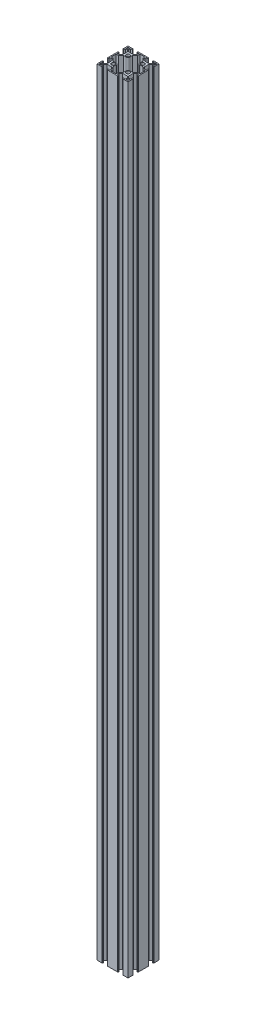
from build123d import *

# Parameters (mm, degrees)
SKETCH1_W                = 60
SKETCH1_H                = 60
BOSS_EXTRUDE1_DEPTH      = 1500
CUT_EXTRUDE1_DEPTH       = 1501.599880048
CIRPATTERN1_COUNT        = 4
CIRPATTERN1_COPY_1_DEPTH = 1501.599880048
CIRPATTERN1_COPY_2_DEPTH = 1501.599880048
CIRPATTERN1_COPY_3_DEPTH = 1501.599880048
SKETCH4_R                = 3.4
CUT_EXTRUDE2_DEPTH       = 1501.599880048
FILLET1_R                = 0.2
FILLET2_R                = 0.2
FILLET3_R                = 0.2
FILLET4_R                = 0.2


with BuildPart() as part:
    # Sketch1 → Boss-Extrude1 (new body)
    with BuildSketch(Plane(origin=(0, 0, 0), x_dir=(1, 0, 0), z_dir=(0, 1, 0))):
        Rectangle(SKETCH1_W, SKETCH1_H)
        Polygon((-23.05, -28), (-6.95, -28), (-6.95, -24.4), (-10.615, -20.8), (-19.385, -20.8), (-23.05, -24.4), align=None, mode=Mode.SUBTRACT)
        Polygon((10.615, -20.8), (19.385, -20.8), (23.05, -24.4), (23.05, -28), (6.95, -28), (6.95, -24.4), align=None, mode=Mode.SUBTRACT)
        Polygon((19.385, 20.8), (23.05, 24.4), (23.05, 28), (6.95, 28), (6.95, 24.4), (10.615, 20.8), align=None, mode=Mode.SUBTRACT)
        Polygon((-23.05, 24.4), (-23.05, 28), (-6.95, 28), (-6.95, 24.4), (-10.615, 20.8), (-19.385, 20.8), align=None, mode=Mode.SUBTRACT)
        Polygon((-20.8, 19.385), (-24.4, 23.05), (-28, 23.05), (-28, 6.95), (-24.4, 6.95), (-20.8, 10.615), align=None, mode=Mode.SUBTRACT)
        Polygon((-24.4, -23.05), (-28, -23.05), (-28, -6.95), (-24.4, -6.95), (-20.8, -10.615), (-20.8, -19.385), align=None, mode=Mode.SUBTRACT)
        Polygon((20.8, -19.385), (24.4, -23.05), (28, -23.05), (28, -6.95), (24.4, -6.95), (20.8, -10.615), align=None, mode=Mode.SUBTRACT)
        Polygon((24.4, 23.05), (28, 23.05), (28, 6.95), (24.4, 6.95), (20.8, 10.615), (20.8, 19.385), align=None, mode=Mode.SUBTRACT)
    extrude(amount=BOSS_EXTRUDE1_DEPTH)

    # Sketch2 → Cut-Extrude1 (cut, through all)
    with BuildSketch(Plane(origin=(0, 1500, 0), x_dir=(1, 0, 0), z_dir=(0, 1, 0))):
        Polygon((-19.1, -28), (-19.1, -29), (-20.1, -29), (-20.1, -30), (-9.9, -30), (-9.9, -29), (-10.9, -29), (-10.9, -28), align=None)
    cut_extrude1 = extrude(amount=-CUT_EXTRUDE1_DEPTH, mode=Mode.SUBTRACT)

    # Mirror1: Cut-Extrude1 across plane
    add(cut_extrude1.mirror(Plane(origin=(0, 0, 0), x_dir=(0, 0, 1), z_dir=(1, 0, 0))), mode=Mode.SUBTRACT)

    # CirPattern1: Cut-Extrude1 ×4 about axis
    cirpattern1_axis = Axis((0, 1050, 0), (0, -1, 0))
    for i in range(1, CIRPATTERN1_COUNT):
        add(cut_extrude1.rotate(cirpattern1_axis, i * 360 / CIRPATTERN1_COUNT), mode=Mode.SUBTRACT)

    # CirPattern1 copy 1 sketch → CirPattern1 copy 1 (cut, through all)
    with BuildSketch(Plane(origin=(0, 1500, 0), x_dir=(0, 0, -1), z_dir=(0, 1, 0))):
        Polygon((-19.1, 28), (-19.1, 29), (-20.1, 29), (-20.1, 30), (-9.9, 30), (-9.9, 29), (-10.9, 29), (-10.9, 28), align=None)
    extrude(amount=-CIRPATTERN1_COPY_1_DEPTH, mode=Mode.SUBTRACT)

    # CirPattern1 copy 2 sketch → CirPattern1 copy 2 (cut, through all)
    with BuildSketch(Plane(origin=(0, 1500, 0), x_dir=(1, 0, 0), z_dir=(0, 1, 0))):
        Polygon((-19.1, 28), (-19.1, 29), (-20.1, 29), (-20.1, 30), (-9.9, 30), (-9.9, 29), (-10.9, 29), (-10.9, 28), align=None)
    extrude(amount=-CIRPATTERN1_COPY_2_DEPTH, mode=Mode.SUBTRACT)

    # CirPattern1 copy 3 sketch → CirPattern1 copy 3 (cut, through all)
    with BuildSketch(Plane.ZX.offset(1500)):
        Polygon((-19.1, 28), (-19.1, 29), (-20.1, 29), (-20.1, 30), (-9.9, 30), (-9.9, 29), (-10.9, 29), (-10.9, 28), align=None)
    extrude(amount=-CIRPATTERN1_COPY_3_DEPTH, mode=Mode.SUBTRACT)

    # Sketch4 → Cut-Extrude2 (cut, through all)
    with BuildSketch(Plane(origin=(0, 1500, 0), x_dir=(1, 0, 0), z_dir=(0, 1, 0))):
        with BuildLine():
            Line((-13.197035349, 9.797035349), (-18.8, 9.797035349))
            Line((-18.8, 9.797035349), (-23.561071557, 4.95))
            Line((-23.561071557, 4.95), (-28, 4.95))
            Line((-28, 4.95), (-28, -4.95))
            Line((-28, -4.95), (-23.561071557, -4.95))
            Line((-23.561071557, -4.95), (-18.8, -9.797035349))
            Line((-18.8, -9.797035349), (-13.197035349, -9.797035349))
            ThreePointArc((-13.197035349, -9.797035349), (-10.792872293, -10.792872293), (-9.797035349, -13.197035349))
            Line((-9.797035349, -13.197035349), (-9.797035349, -18.8))
            Line((-9.797035349, -18.8), (-4.95, -23.561071557))
            Line((-4.95, -23.561071557), (-4.95, -28))
            Line((-4.95, -28), (4.95, -28))
            Line((4.95, -28), (4.95, -23.561071557))
            Line((4.95, -23.561071557), (9.797035349, -18.8))
            Line((9.797035349, -18.8), (9.797035349, -13.197035349))
            ThreePointArc((9.797035349, -13.197035349), (10.792872293, -10.792872293), (13.197035349, -9.797035349))
            Line((13.197035349, -9.797035349), (18.8, -9.797035349))
            Line((18.8, -9.797035349), (23.561071557, -4.95))
            Line((23.561071557, -4.95), (28, -4.95))
            Line((28, -4.95), (28, 4.95))
            Line((28, 4.95), (23.561071557, 4.95))
            Line((23.561071557, 4.95), (18.8, 9.797035349))
            Line((18.8, 9.797035349), (13.197035349, 9.797035349))
            ThreePointArc((13.197035349, 9.797035349), (10.792872293, 10.792872293), (9.797035349, 13.197035349))
            Line((9.797035349, 13.197035349), (9.797035349, 18.8))
            Line((9.797035349, 18.8), (4.95, 23.561071557))
            Line((4.95, 23.561071557), (4.95, 28))
            Line((4.95, 28), (-4.95, 28))
            Line((-4.95, 28), (-4.95, 23.561071557))
            Line((-4.95, 23.561071557), (-9.797035349, 18.8))
            Line((-9.797035349, 18.8), (-9.797035349, 13.197035349))
            ThreePointArc((-9.797035349, 13.197035349), (-10.792872293, 10.792872293), (-13.197035349, 9.797035349))
        make_face()
        with BuildLine():
            ThreePointArc((-28, -27.5), (-27.853553391, -27.853553391), (-27.5, -28))
            Line((-27.5, -28), (-24.9, -28))
            ThreePointArc((-24.9, -28), (-24.546446609, -27.853553391), (-24.4, -27.5))
            Line((-24.4, -27.5), (-24.4, -24.9))
            ThreePointArc((-24.4, -24.9), (-24.546446609, -24.546446609), (-24.9, -24.4))
            Line((-24.9, -24.4), (-27.5, -24.4))
            ThreePointArc((-27.5, -24.4), (-27.853553391, -24.546446609), (-28, -24.9))
            Line((-28, -24.9), (-28, -27.5))
        make_face()
        with BuildLine():
            ThreePointArc((24.4, -27.5), (24.546446609, -27.853553391), (24.9, -28))
            Line((24.9, -28), (27.5, -28))
            ThreePointArc((27.5, -28), (27.853553391, -27.853553391), (28, -27.5))
            Line((28, -27.5), (28, -24.9))
            ThreePointArc((28, -24.9), (27.853553391, -24.546446609), (27.5, -24.4))
            Line((27.5, -24.4), (24.9, -24.4))
            ThreePointArc((24.9, -24.4), (24.546446609, -24.546446609), (24.4, -24.9))
            Line((24.4, -24.9), (24.4, -27.5))
        make_face()
        with BuildLine():
            ThreePointArc((-27.5, 28), (-27.853553391, 27.853553391), (-28, 27.5))
            Line((-28, 27.5), (-28, 24.9))
            ThreePointArc((-28, 24.9), (-27.853553391, 24.546446609), (-27.5, 24.4))
            Line((-27.5, 24.4), (-24.9, 24.4))
            ThreePointArc((-24.9, 24.4), (-24.546446609, 24.546446609), (-24.4, 24.9))
            Line((-24.4, 24.9), (-24.4, 27.5))
            ThreePointArc((-24.4, 27.5), (-24.546446609, 27.853553391), (-24.9, 28))
            Line((-24.9, 28), (-27.5, 28))
        make_face()
        with BuildLine():
            ThreePointArc((28, 27.5), (27.853553391, 27.853553391), (27.5, 28))
            Line((27.5, 28), (24.9, 28))
            ThreePointArc((24.9, 28), (24.546446609, 27.853553391), (24.4, 27.5))
            Line((24.4, 27.5), (24.4, 24.9))
            ThreePointArc((24.4, 24.9), (24.546446609, 24.546446609), (24.9, 24.4))
            Line((24.9, 24.4), (27.5, 24.4))
            ThreePointArc((27.5, 24.4), (27.853553391, 24.546446609), (28, 24.9))
            Line((28, 24.9), (28, 27.5))
        make_face()
        with Locations((14.298517674, 14.298517674)):
            Circle(SKETCH4_R)
        with Locations((14.298517674, -14.298517674)):
            Circle(SKETCH4_R)
        with Locations((-14.298517674, -14.298517674)):
            Circle(SKETCH4_R)
        with Locations((-14.298517674, 14.298517674)):
            Circle(SKETCH4_R)
    extrude(amount=-CUT_EXTRUDE2_DEPTH, mode=Mode.SUBTRACT)

    # Fillet1
    fillet1_edges = [part.edges().sort_by_distance(p)[0] for p in [
        (28, 750, -19.1),
        (30, 750, -20.1),
        (29, 750, -20.1),
        (29, 750, -19.1),
        (28, 750, 10.9),
        (29, 750, 9.9),
        (28, 750, 19.1),
        (29, 750, 20.1),
        (30, 750, 20.1),
        (29, 750, 19.1),
        (29, 750, 10.9),
        (30, 750, 9.9),
        (30, 750, -9.9),
        (29, 750, -9.9),
        (29, 750, -10.9),
        (28, 750, -10.9),
    ]]
    fillet(fillet1_edges, radius=FILLET1_R)

    # Fillet2
    fillet2_edges = [part.edges().sort_by_distance(p)[0] for p in [
        (-20.1, 0, -29.5),
        (-20.1, 1500, -29.5),
        (-20.1, 750, -29),
        (-19.6, 0, -29),
        (-19.1, 750, -29),
        (-19.6, 1500, -29),
        (-9.9, 750, -30),
        (-10.9, 750, -28),
        (-10.9, 750, -29),
        (-9.9, 750, -29),
        (19.1, 750, -28),
        (19.1, 750, -29),
        (20.1, 750, -29),
        (20.1, 750, -30),
        (10.9, 750, -28),
        (10.9, 750, -29),
        (9.9, 750, -29),
        (9.9, 750, -30),
        (-19.1, 750, -28),
        (-20.1, 750, -30),
    ]]
    fillet(fillet2_edges, radius=FILLET2_R)

    # Fillet3
    fillet3_edges = [part.edges().sort_by_distance(p)[0] for p in [
        (-29, 750, 9.9),
        (-29, 750, -20.1),
        (-30, 750, -20.1),
        (-29, 750, -19.1),
        (-28, 750, -10.9),
        (-29, 750, -10.9),
        (-29, 750, -9.9),
        (-30, 750, -9.9),
        (-29, 750, 10.9),
        (-30, 750, 9.9),
        (-28, 750, 19.1),
        (-29, 750, 19.1),
        (-29, 750, 20.1),
        (-30, 750, 20.1),
    ]]
    fillet(fillet3_edges, radius=FILLET3_R)

    # Fillet4
    fillet4_edges = [part.edges().sort_by_distance(p)[0] for p in [
        (-19.1, 750, 28),
        (10.9, 750, 28),
        (19.1, 750, 28),
        (20.1, 750, 29),
        (-10.9, 750, 28),
        (-9.9, 750, 29),
        (9.9, 750, 29),
        (-20.1, 750, 29),
        (19.1, 750, 29),
        (20.1, 750, 30),
        (10.9, 750, 29),
        (9.9, 750, 30),
        (-9.9, 750, 30),
        (-10.9, 750, 29),
        (-19.1, 750, 29),
        (-20.1, 750, 30),
    ]]
    fillet(fillet4_edges, radius=FILLET4_R)


solid = part.part
